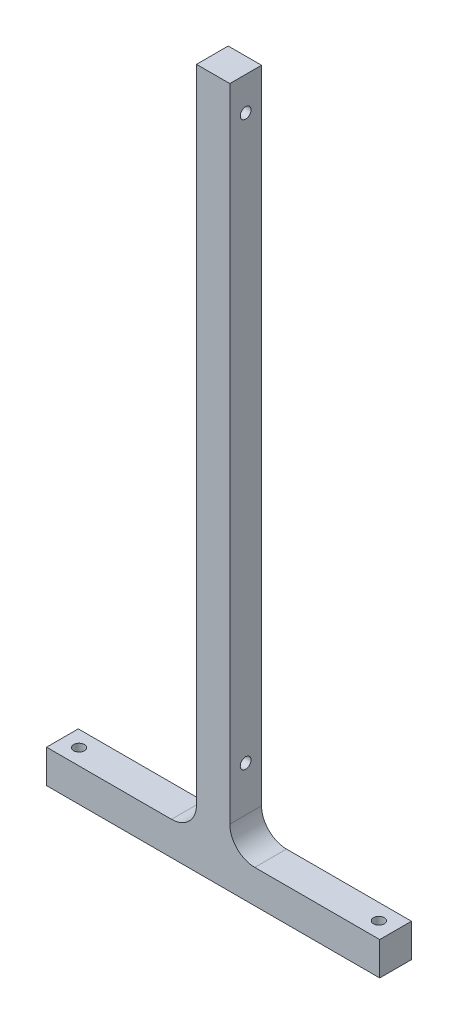
from build123d import *

# Parameters (mm, degrees)
BOSS_EXTRUDE1_DEPTH = 9.525
FILLET1_R           = 7.5
SKETCH2_R           = 1.625
CUT_EXTRUDE1_DEPTH  = 11
SKETCH3_R           = 1.625
CUT_EXTRUDE2_DEPTH  = 56


with BuildPart() as part:
    # Sketch1 → Boss-Extrude1 (new body)
    with BuildSketch(Plane.XY):
        Polygon((-50, 0), (50, 0), (50, 10), (5, 10), (5, 210), (-5, 210), (-5, 10), (-50, 10), align=None)
    extrude(amount=BOSS_EXTRUDE1_DEPTH)

    # Fillet1
    fillet1_edges = [part.edges().sort_by_distance(p)[0] for p in [
        (-5, 10, 4.7625),
        (5, 10, 4.7625),
    ]]
    fillet(fillet1_edges, radius=FILLET1_R)

    # Sketch2 → Cut-Extrude1 (cut, through all)
    with BuildSketch(Plane(origin=(0, 10, 0), x_dir=(1, 0, 0), z_dir=(0, 1, 0))):
        with Locations((-45, -4.7625)):
            Circle(SKETCH2_R)
        with Locations((45, -4.7625)):
            Circle(SKETCH2_R)
    extrude(amount=-CUT_EXTRUDE1_DEPTH, mode=Mode.SUBTRACT)

    # Sketch3 → Cut-Extrude2 (cut, through all)
    with BuildSketch(Plane.ZY.offset(5)):
        with Locations((4.7625, 31)):
            Circle(SKETCH3_R)
        with Locations((4.7625, 200)):
            Circle(SKETCH3_R)
    extrude(amount=-CUT_EXTRUDE2_DEPTH, mode=Mode.SUBTRACT)


solid = part.part
